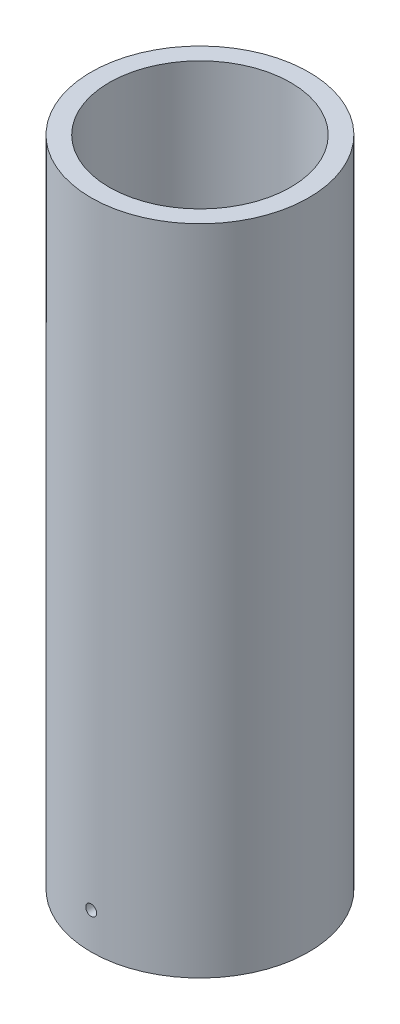
from build123d import *

# Parameters (mm, degrees)
SKETCH1_R               = 30
SKETCH1_R_2             = 25
BOSS_EXTRUDE1_DEPTH     = 180
SKETCH2_R               = 1.5
CUT_EXTRUDE1_DEPTH      = 31
CUT_EXTRUDE1_DEPTH_BACK = 31


with BuildPart() as part:
    # Sketch1 → Boss-Extrude1 (new body)
    with BuildSketch(Plane(origin=(0, 0, 0), x_dir=(1, 0, 0), z_dir=(0, 1, 0))):
        Circle(SKETCH1_R)
        Circle(SKETCH1_R_2, mode=Mode.SUBTRACT)
    extrude(amount=BOSS_EXTRUDE1_DEPTH)

    # Sketch2 → Cut-Extrude1 (cut, two sides)
    with BuildSketch(Plane.XY) as cut_extrude1_sk:
        with Locations((0, 10)):
            Circle(SKETCH2_R)
    extrude(amount=CUT_EXTRUDE1_DEPTH, mode=Mode.SUBTRACT)
    extrude(cut_extrude1_sk.sketch, amount=-CUT_EXTRUDE1_DEPTH_BACK, mode=Mode.SUBTRACT)


solid = part.part
